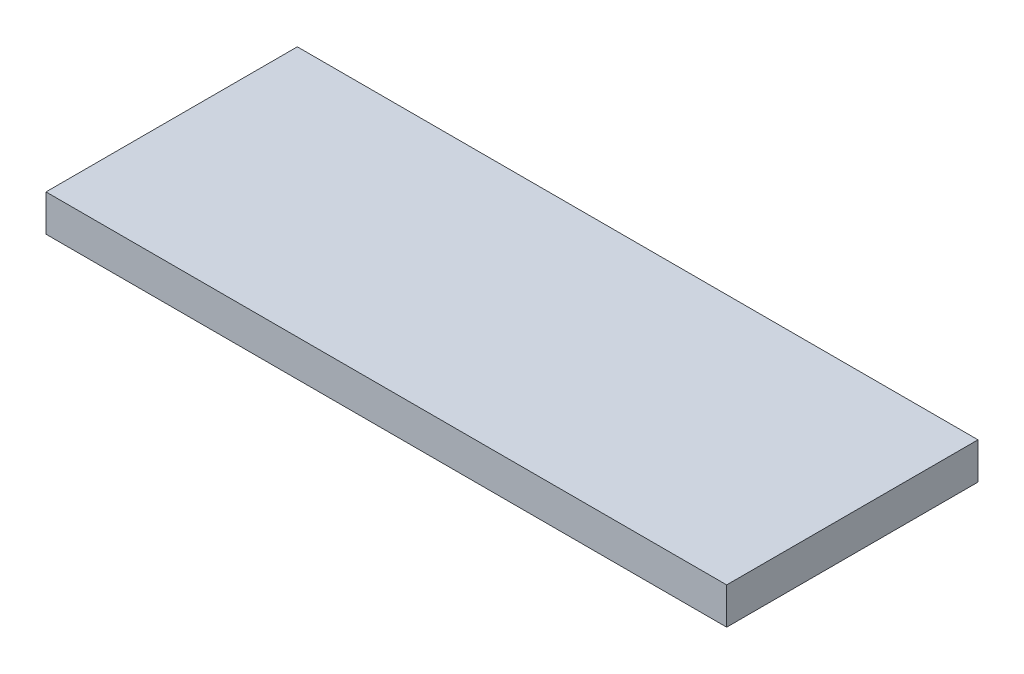
from build123d import *

# Parameters (mm, degrees)
SKETCH1_W           = 325
SKETCH1_H           = 120
BOSS_EXTRUDE1_DEPTH = 17.5


with BuildPart() as part:
    # Sketch1 → Boss-Extrude1 (new body)
    with BuildSketch(Plane(origin=(0, 0, 0), x_dir=(1, 0, 0), z_dir=(0, 1, 0))):
        Rectangle(SKETCH1_W, SKETCH1_H)
    extrude(amount=BOSS_EXTRUDE1_DEPTH)


solid = part.part
